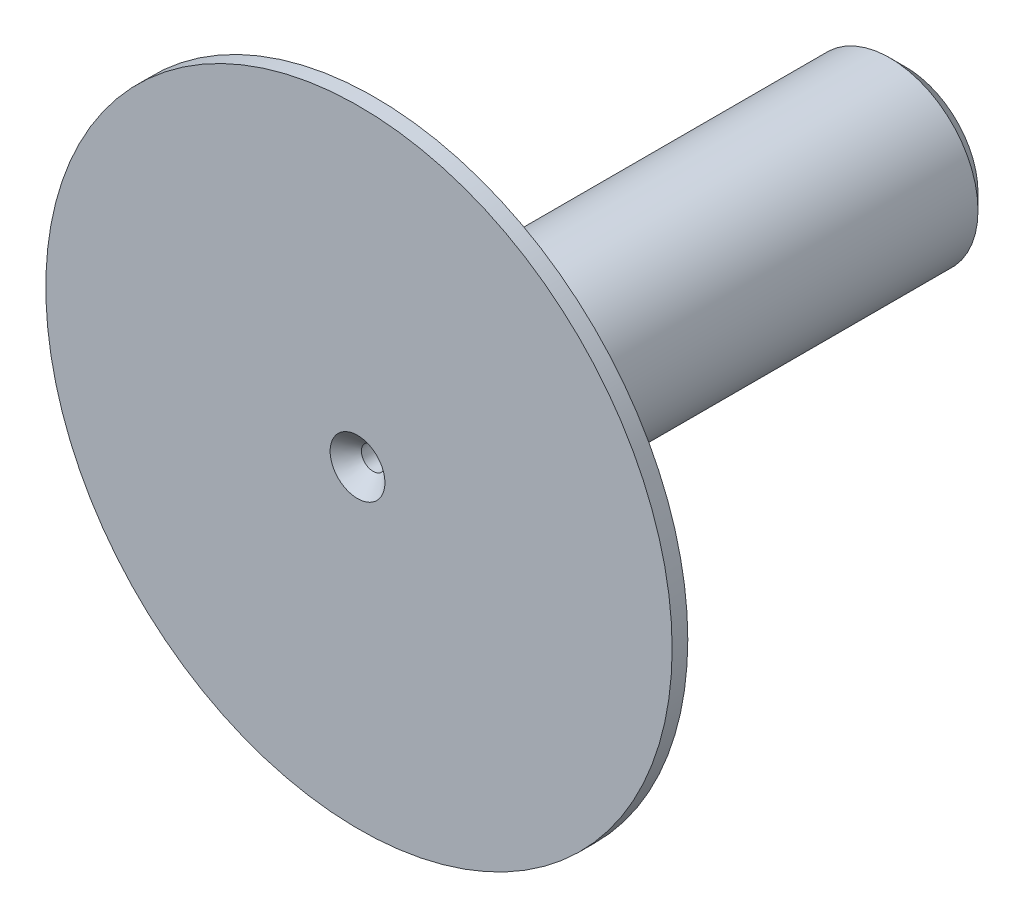
from build123d import *

# Parameters (mm, degrees)
SKETCH1_R           = 1.125
SKETCH1_R_2         = 0.15
BOSS_EXTRUDE1_DEPTH = 7
SKETCH2_R           = 4
SKETCH2_R_2         = 1.125
BOSS_EXTRUDE2_DEPTH = 0.2
CHAMFER1_SIZE       = 0.2


with BuildPart() as part:
    # Sketch1 → Boss-Extrude1 (new body)
    with BuildSketch(Plane.XY):
        Circle(SKETCH1_R)
        Circle(SKETCH1_R_2, mode=Mode.SUBTRACT)
    extrude(amount=BOSS_EXTRUDE1_DEPTH)

    # Sketch2 → Boss-Extrude2 (add)
    with BuildSketch(Plane.XY.offset(7)):
        with Locations((0.018669882, 0)):
            Circle(SKETCH2_R)
        Circle(SKETCH2_R_2, mode=Mode.SUBTRACT)
    extrude(amount=-BOSS_EXTRUDE2_DEPTH)

    # Chamfer1
    chamfer1_edges = [part.edges().sort_by_distance(p)[0] for p in [
        (-1.125, 0, 0),
        (-0.15, 0, 0),
        (-0.15, 0, 7),
    ]]
    chamfer(chamfer1_edges, length=CHAMFER1_SIZE)


solid = part.part
